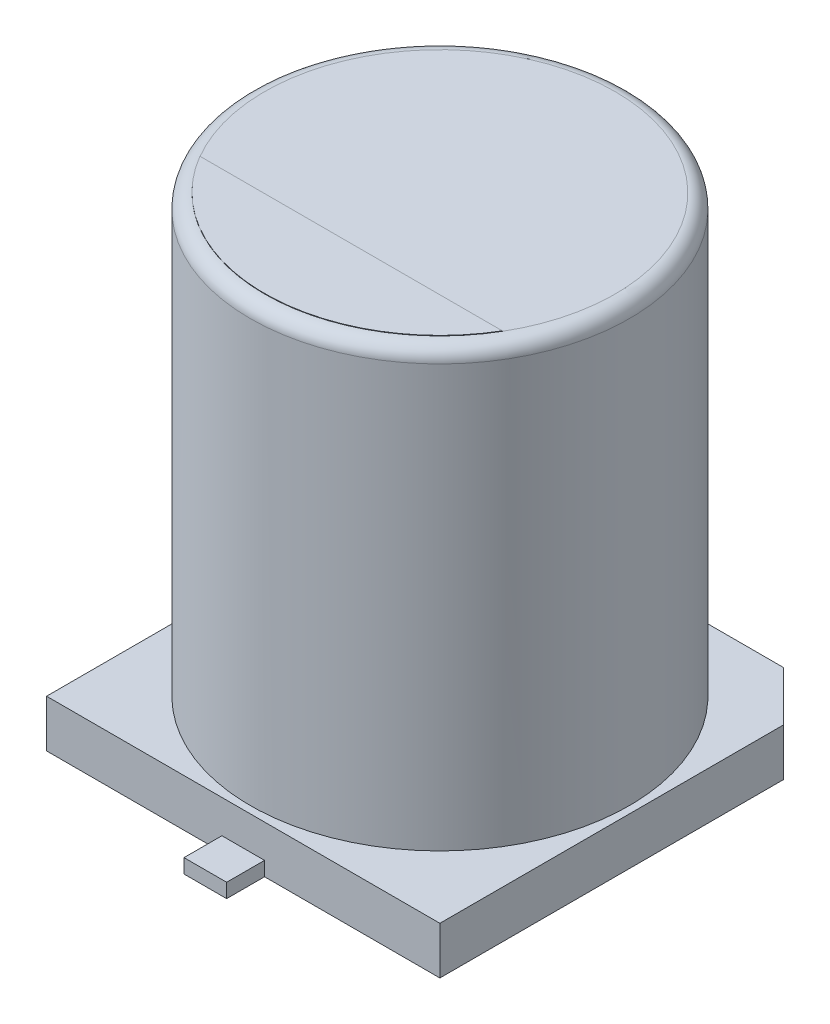
from build123d import *

# Parameters (mm, degrees)
BOSS_EXTRUDE1_DEPTH = 1
SKETCH3_R           = 4
BOSS_EXTRUDE2_DEPTH = 10.2
FILLET1_R           = 0.3
SKETCH4_W           = 0.9
SKETCH4_H           = 3.4
BOSS_EXTRUDE3_DEPTH = 0.3
BOSS_EXTRUDE4_DEPTH = 0.01


with BuildPart() as part:
    # Sketch2 → Boss-Extrude1 (new body)
    with BuildSketch(Plane(origin=(0, 0, 0), x_dir=(1, 0, 0), z_dir=(0, 1, 0))):
        Polygon((4.15, -4.15), (-4.15, -4.15), (-4.15, 3.1), (-3.1, 4.15), (3.1, 4.15), (4.15, 3.1), align=None)
    extrude(amount=BOSS_EXTRUDE1_DEPTH)

    # Sketch3 → Boss-Extrude2 (add)
    with BuildSketch(Plane(origin=(0, 0, 0), x_dir=(1, 0, 0), z_dir=(0, 1, 0))):
        Circle(SKETCH3_R)
    extrude(amount=BOSS_EXTRUDE2_DEPTH)

    # Fillet1
    fillet1_edges = [part.edges().sort_by_distance(p)[0] for p in [
        (-4, 10.2, 0),
    ]]
    fillet(fillet1_edges, radius=FILLET1_R)

    # Sketch4 → Boss-Extrude3 (add)
    with BuildSketch(Plane(origin=(0, 0, 0), x_dir=(1, 0, 0), z_dir=(0, 1, 0))):
        with Locations((0, 3.25)):
            Rectangle(SKETCH4_W, SKETCH4_H)
        with Locations((0, -3.25)):
            Rectangle(SKETCH4_W, SKETCH4_H)
    extrude(amount=BOSS_EXTRUDE3_DEPTH)

    # Sketch5 → Boss-Extrude4 (add)
    with BuildSketch(Plane(origin=(0, 10.2, 0), x_dir=(1, 0, 0), z_dir=(0, 1, 0))):
        with BuildLine():
            Line((-3.190682189, -1.873378544), (3.190682189, -1.873378544))
            ThreePointArc((3.190682189, -1.873378544), (0, -3.7), (-3.190682189, -1.873378544))
        make_face()
    extrude(amount=BOSS_EXTRUDE4_DEPTH)


solid = part.part
